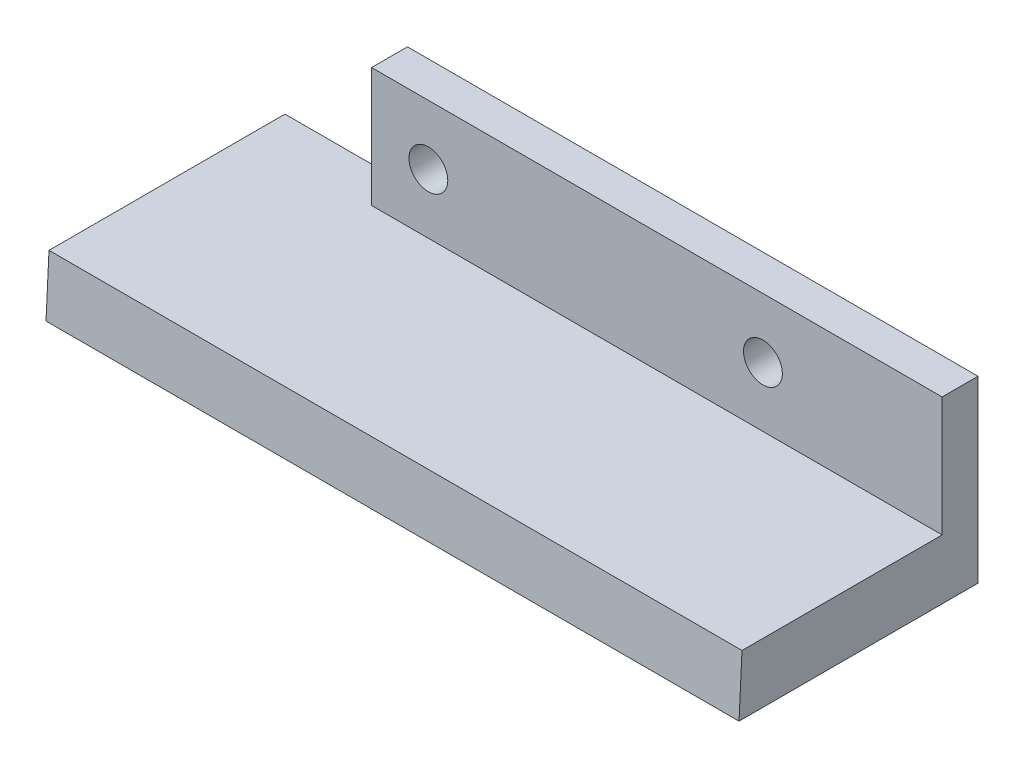
from build123d import *

# Parameters (mm, degrees)
ESQUISSE1_W             = 58
ESQUISSE1_H             = 5
BOSS_EXTRU_1_DEPTH      = 20
ESQUISSE3_W             = 47.75
ESQUISSE3_H             = 3
BOSS_EXTRU_2_DEPTH      = 10
ESQUISSE4_R             = 1.625
ENL_V_MAT_EXTRU_1_DEPTH = 10
ENL_V_MAT_EXTRU_2_DEPTH = 59


with BuildPart() as part:
    # Esquisse1 → Boss.-Extru.1 (new body)
    with BuildSketch(Plane.XY):
        with Locations((29, -2.5)):
            Rectangle(ESQUISSE1_W, ESQUISSE1_H)
    extrude(amount=BOSS_EXTRU_1_DEPTH)

    # Esquisse3 → Boss.-Extru.2 (add)
    with BuildSketch(Plane(origin=(0, 0, 0), x_dir=(1, 0, 0), z_dir=(0, 1, 0))):
        with Locations((34.125, -1.5)):
            Rectangle(ESQUISSE3_W, ESQUISSE3_H)
    extrude(amount=BOSS_EXTRU_2_DEPTH)

    # Esquisse4 → Enlèv. mat.-Extru.1 (cut)
    with BuildSketch(Plane.XY.offset(3)):
        with Locations((43, 5)):
            Circle(ESQUISSE4_R)
        with Locations((15, 5)):
            Circle(ESQUISSE4_R)
    extrude(amount=-ENL_V_MAT_EXTRU_1_DEPTH, mode=Mode.SUBTRACT)

    # Esquisse6 → Enlèv. mat.-Extru.2 (cut, through all)
    with BuildSketch(Plane(origin=(58, 0, 0), x_dir=(0, 0, -1), z_dir=(1, 0, 0))):
        Polygon((-20, -5), (-19.75, 0), (-20, 0), align=None)
    extrude(amount=-ENL_V_MAT_EXTRU_2_DEPTH, mode=Mode.SUBTRACT)


solid = part.part
